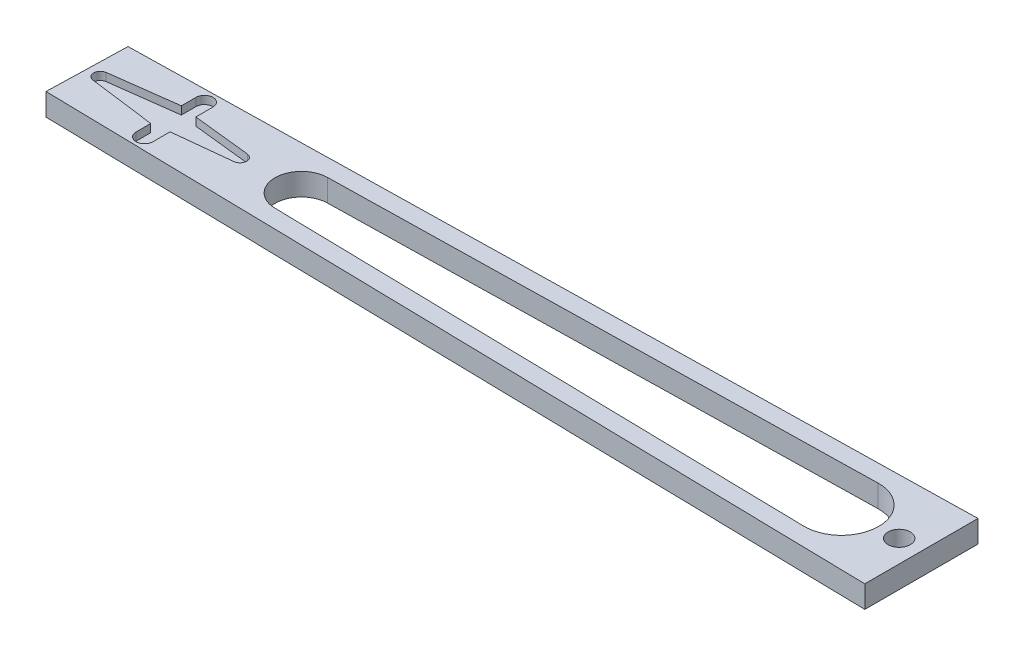
from build123d import *

# Parameters (mm, degrees)
SKETCH1_R           = 2.5
BOSS_EXTRUDE1_DEPTH = 5
BOSS_EXTRUDE2_DEPTH = 3.2


with BuildPart() as part:
    # Sketch1 → Boss-Extrude1 (new body)
    with BuildSketch(Plane(origin=(0, 0, 0), x_dir=(1, 0, 0), z_dir=(0, 1, 0))):
        Polygon((-90.005103209, -41.999399148), (-90.480022259, -59.993132832), (97.6446575, -63.815482804), (97.6446575, -38.32994317), (-49.807795153, -41.213348306), align=None)
        with BuildLine():
            Line((-72.450254412, -47.547483492), (-72.450254412, -44.247483492))
            ThreePointArc((-72.450254412, -44.247483492), (-70.550254412, -42.347483492), (-68.650254412, -44.247483492))
            Line((-68.650254412, -44.247483492), (-68.650254412, -48.097483492))
            Line((-68.650254412, -48.097483492), (-55.644843725, -49.510975235))
            ThreePointArc((-55.644843725, -49.510975235), (-54.299665811, -51.008287292), (-55.640888759, -52.509143053))
            Line((-55.640888759, -52.509143053), (-68.650254412, -53.897483492))
            Line((-68.650254412, -53.897483492), (-68.650254412, -57.747483492))
            ThreePointArc((-68.650254412, -57.747483492), (-70.550254412, -59.647483492), (-72.450254412, -57.747483492))
            Line((-72.450254412, -57.747483492), (-72.450254412, -54.447483492))
            Line((-72.450254412, -54.447483492), (-87.444932153, -52.484796699))
            ThreePointArc((-87.444932153, -52.484796699), (-88.750254412, -50.997483492), (-87.444932153, -49.510170284))
            Line((-87.444932153, -49.510170284), (-72.450254412, -47.547483492))
        make_face(mode=Mode.SUBTRACT)
        with BuildLine():
            Line((-42.056384532, -45.062535629), (79.480798132, -42.685898751))
            ThreePointArc((79.480798132, -42.685898751), (88.025749222, -51.068799274), (79.473979342, -59.444743533))
            Line((79.473979342, -59.444743533), (-42.061229083, -56.969206079))
            ThreePointArc((-42.061229083, -56.969206079), (-47.894488465, -51.013496449), (-42.056384532, -45.062535629))
        make_face(mode=Mode.SUBTRACT)
        with Locations((92.6446575, -51.070678602)):
            Circle(SKETCH1_R, mode=Mode.SUBTRACT)
    extrude(amount=BOSS_EXTRUDE1_DEPTH)

    # Sketch1_16 → Boss-Extrude2 (add)
    with BuildSketch(Plane(origin=(0, 0, 0), x_dir=(1, 0, 0), z_dir=(0, 1, 0))):
        with BuildLine():
            Line((-72.450254412, -44.247483492), (-72.450254412, -47.547483492))
            Line((-72.450254412, -47.547483492), (-87.444932153, -49.510170284))
            ThreePointArc((-87.444932153, -49.510170284), (-88.750254412, -50.997483492), (-87.444932153, -52.484796699))
            Line((-87.444932153, -52.484796699), (-72.450254412, -54.447483492))
            Line((-72.450254412, -54.447483492), (-72.450254412, -57.747483492))
            ThreePointArc((-72.450254412, -57.747483492), (-70.550254412, -59.647483492), (-68.650254412, -57.747483492))
            Line((-68.650254412, -57.747483492), (-68.650254412, -53.897483492))
            Line((-68.650254412, -53.897483492), (-55.640888759, -52.509143053))
            ThreePointArc((-55.640888759, -52.509143053), (-54.299665811, -51.008287292), (-55.644843725, -49.510975235))
            Line((-55.644843725, -49.510975235), (-68.650254412, -48.097483492))
            Line((-68.650254412, -48.097483492), (-68.650254412, -44.247483492))
            ThreePointArc((-68.650254412, -44.247483492), (-70.550254412, -42.347483492), (-72.450254412, -44.247483492))
        make_face()
    extrude(amount=BOSS_EXTRUDE2_DEPTH)


solid = part.part
